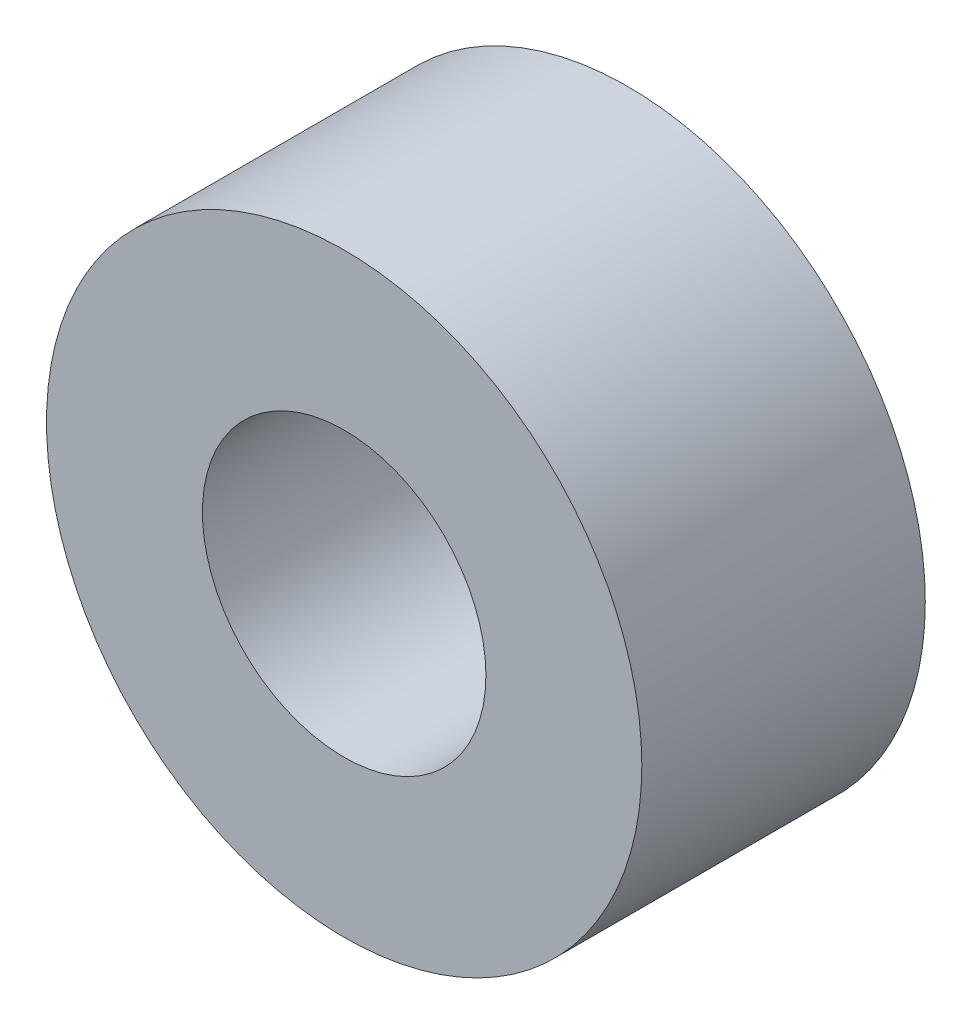
from build123d import *

# Parameters (mm, degrees)
SKETCH1_R           = 10.5
SKETCH1_R_2         = 5
BOSS_EXTRUDE1_DEPTH = 10


with BuildPart() as part:
    # Sketch1 → Boss-Extrude1 (new body)
    with BuildSketch(Plane.XY):
        Circle(SKETCH1_R)
        Circle(SKETCH1_R_2, mode=Mode.SUBTRACT)
    extrude(amount=BOSS_EXTRUDE1_DEPTH)


solid = part.part
